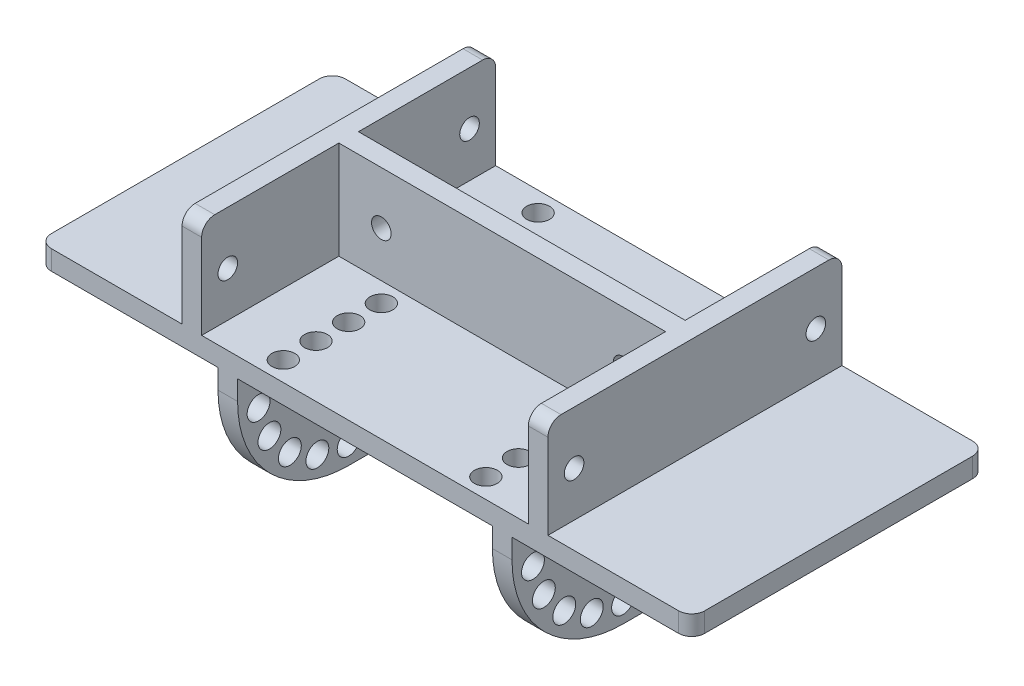
from build123d import *

# Parameters (mm, degrees)
SKETCH1_W               = 100
SKETCH1_H               = 45
BOSS_EXTRUDE1_DEPTH     = 3
BOSS_EXTRUDE2_DEPTH     = 15
SKETCH4_R               = 1.5
CUT_EXTRUDE1_DEPTH      = 79
SKETCH5_R               = 1.5
CUT_EXTRUDE2_DEPTH      = 25
FILLET1_R               = 2
SKETCH6_W               = 3
SKETCH6_H               = 45
BOSS_EXTRUDE3_DEPTH     = 20
FILLET2_R               = 17
SKETCH7_R               = 1.75
CUT_EXTRUDE3_DEPTH      = 73.5
CIRPATTERN1_COUNT       = 5
CIRPATTERN1_ANGLE       = 80
MIRROR1_COPY_1_SKETCH_R = 1.75
MIRROR1_COPY_1_DEPTH    = 73.5
MIRROR1_COPY_2_SKETCH_R = 1.75
MIRROR1_COPY_2_DEPTH    = 73.5
MIRROR1_COPY_3_SKETCH_R = 1.75
MIRROR1_COPY_3_DEPTH    = 73.5
MIRROR1_COPY_4_SKETCH_R = 1.75
MIRROR1_COPY_4_DEPTH    = 73.5
SKETCH8_R               = 1.75
CUT_EXTRUDE4_DEPTH      = 24
LPATTERN1_COUNT         = 4
LPATTERN1_PITCH         = 5
MIRROR2_COPY_1_SKETCH_R = 1.75
MIRROR2_COPY_1_DEPTH    = 24
MIRROR2_COPY_2_SKETCH_R = 1.75
MIRROR2_COPY_2_DEPTH    = 24
MIRROR2_COPY_3_SKETCH_R = 1.75
MIRROR2_COPY_3_DEPTH    = 24


with BuildPart() as part:
    # Sketch1 → Boss-Extrude1 (new body)
    with BuildSketch(Plane(origin=(0, 0, 0), x_dir=(1, 0, 0), z_dir=(0, 1, 0))):
        Rectangle(SKETCH1_W, SKETCH1_H)
    extrude(amount=BOSS_EXTRUDE1_DEPTH)

    # Sketch2 → Boss-Extrude2 (add)
    with BuildSketch(Plane(origin=(0, 3, 0), x_dir=(1, 0, 0), z_dir=(0, 1, 0))):
        Polygon((-25, 22.5), (-28, 22.5), (-28, -22.5), (-25, -22.5), (-25, -1.5), (25, -1.5), (25, -22.5), (28, -22.5), (28, 22.5), (25, 22.5), (25, 1.5), (-25, 1.5), align=None)
    extrude(amount=BOSS_EXTRUDE2_DEPTH)

    # Sketch4 → Cut-Extrude1 (cut, through all)
    with BuildSketch(Plane.ZY.offset(28)):
        with Locations((-18.5, 9.88505799)):
            Circle(SKETCH4_R)
        with Locations((18.5, 9.88505799)):
            Circle(SKETCH4_R)
    extrude(amount=-CUT_EXTRUDE1_DEPTH, mode=Mode.SUBTRACT)

    # Sketch5 → Cut-Extrude2 (cut, through all)
    with BuildSketch(Plane.XY.offset(1.5)):
        with Locations((-18.5, 9.963459829)):
            Circle(SKETCH5_R)
        with Locations((18.5, 9.963459829)):
            Circle(SKETCH5_R)
    extrude(amount=-CUT_EXTRUDE2_DEPTH, mode=Mode.SUBTRACT)

    # Fillet1
    fillet1_edges = [part.edges().sort_by_distance(p)[0] for p in [
        (-26.5, 18, 22.5),
        (26.5, 18, 22.5),
        (26.5, 18, -22.5),
        (-26.5, 18, -22.5),
        (50, 1.5, 22.5),
        (-50, 1.5, 22.5),
        (-50, 1.5, -22.5),
        (50, 1.5, -22.5),
    ]]
    fillet(fillet1_edges, radius=FILLET1_R)

    # Sketch6 → Boss-Extrude3 (add)
    with BuildSketch(Plane.XZ):
        with Locations((-21, 0)):
            Rectangle(SKETCH6_W, SKETCH6_H)
        with Locations((21, 0)):
            Rectangle(SKETCH6_W, SKETCH6_H)
    extrude(amount=BOSS_EXTRUDE3_DEPTH)

    # Fillet2
    fillet2_edges = [part.edges().sort_by_distance(p)[0] for p in [
        (-21, -20, 22.5),
        (-21, -20, -22.5),
        (21, -20, -22.5),
        (21, -20, 22.5),
    ]]
    fillet(fillet2_edges, radius=FILLET2_R)

    # Sketch7 → Cut-Extrude3 (cut, through all)
    with BuildSketch(Plane(origin=(22.5, 0, 0), x_dir=(0, 0, -1), z_dir=(1, 0, 0))):
        with Locations((5.5, -17)):
            Circle(SKETCH7_R)
    cut_extrude3 = extrude(amount=-CUT_EXTRUDE3_DEPTH, mode=Mode.SUBTRACT)

    # CirPattern1: Cut-Extrude3 ×5 about axis
    cirpattern1_axis = Axis((0, -3, -5.5), (1, 0, 0))
    for i in range(1, CIRPATTERN1_COUNT):
        add(cut_extrude3.rotate(cirpattern1_axis, i * CIRPATTERN1_ANGLE / (CIRPATTERN1_COUNT - 1)), mode=Mode.SUBTRACT)

    # Mirror1: Cut-Extrude3 across plane
    add(cut_extrude3.mirror(Plane.XY), mode=Mode.SUBTRACT)

    # Mirror1 copy 1 sketch → Mirror1 copy 1 (cut, through all)
    with BuildSketch(Plane(origin=(22.5, -2.062032926, -0.694369844), x_dir=(0, 0.342020143, 0.939692621), z_dir=(1, 0, 0))):
        with Locations((5.5, 17)):
            Circle(MIRROR1_COPY_1_SKETCH_R)
    extrude(amount=-MIRROR1_COPY_1_DEPTH, mode=Mode.SUBTRACT)

    # Mirror1 copy 2 sketch → Mirror1 copy 2 (cut, through all)
    with BuildSketch(Plane(origin=(22.5, -4.237198524, -0.641607266), x_dir=(0, 0.64278761, 0.766044443), z_dir=(1, 0, 0))):
        with Locations((5.5, 17)):
            Circle(MIRROR1_COPY_2_SKETCH_R)
    extrude(amount=-MIRROR1_COPY_2_DEPTH, mode=Mode.SUBTRACT)

    # Mirror1 copy 3 sketch → Mirror1 copy 3 (cut, through all)
    with BuildSketch(Plane(origin=(22.5, -6.263139721, 0.151923789), x_dir=(0, 0.866025404, 0.5), z_dir=(1, 0, 0))):
        with Locations((5.5, 17)):
            Circle(MIRROR1_COPY_3_SKETCH_R)
    extrude(amount=-MIRROR1_COPY_3_DEPTH, mode=Mode.SUBTRACT)

    # Mirror1 copy 4 sketch → Mirror1 copy 4 (cut, through all)
    with BuildSketch(Plane(origin=(22.5, -7.895498109, 1.590511764), x_dir=(0, 0.984807753, 0.173648178), z_dir=(1, 0, 0))):
        with Locations((5.5, 17)):
            Circle(MIRROR1_COPY_4_SKETCH_R)
    extrude(amount=-MIRROR1_COPY_4_DEPTH, mode=Mode.SUBTRACT)

    # Sketch8 → Cut-Extrude4 (cut, through all)
    with BuildSketch(Plane(origin=(0, 3, 0), x_dir=(1, 0, 0), z_dir=(0, 1, 0))):
        with Locations((-15.5, 19.5)):
            Circle(SKETCH8_R)
        with Locations((15.5, 19.5)):
            Circle(SKETCH8_R)
    cut_extrude4 = extrude(amount=-CUT_EXTRUDE4_DEPTH, mode=Mode.SUBTRACT)

    # LPattern1: Cut-Extrude4 ×4
    with Locations(*[(0, 0, i * LPATTERN1_PITCH) for i in range(1, LPATTERN1_COUNT)]):
        add(cut_extrude4, mode=Mode.SUBTRACT)

    # Mirror2: Cut-Extrude4 across plane
    add(cut_extrude4.mirror(Plane.XY), mode=Mode.SUBTRACT)

    # Mirror2 copy 1 sketch → Mirror2 copy 1 (cut, through all)
    with BuildSketch(Plane(origin=(0, 3, -5), x_dir=(1, 0, 0), z_dir=(0, 1, 0))):
        with Locations((-15.5, -19.5)):
            Circle(MIRROR2_COPY_1_SKETCH_R)
        with Locations((15.5, -19.5)):
            Circle(MIRROR2_COPY_1_SKETCH_R)
    extrude(amount=-MIRROR2_COPY_1_DEPTH, mode=Mode.SUBTRACT)

    # Mirror2 copy 2 sketch → Mirror2 copy 2 (cut, through all)
    with BuildSketch(Plane(origin=(0, 3, -10), x_dir=(1, 0, 0), z_dir=(0, 1, 0))):
        with Locations((-15.5, -19.5)):
            Circle(MIRROR2_COPY_2_SKETCH_R)
        with Locations((15.5, -19.5)):
            Circle(MIRROR2_COPY_2_SKETCH_R)
    extrude(amount=-MIRROR2_COPY_2_DEPTH, mode=Mode.SUBTRACT)

    # Mirror2 copy 3 sketch → Mirror2 copy 3 (cut, through all)
    with BuildSketch(Plane(origin=(0, 3, -15), x_dir=(1, 0, 0), z_dir=(0, 1, 0))):
        with Locations((-15.5, -19.5)):
            Circle(MIRROR2_COPY_3_SKETCH_R)
        with Locations((15.5, -19.5)):
            Circle(MIRROR2_COPY_3_SKETCH_R)
    extrude(amount=-MIRROR2_COPY_3_DEPTH, mode=Mode.SUBTRACT)


solid = part.part
